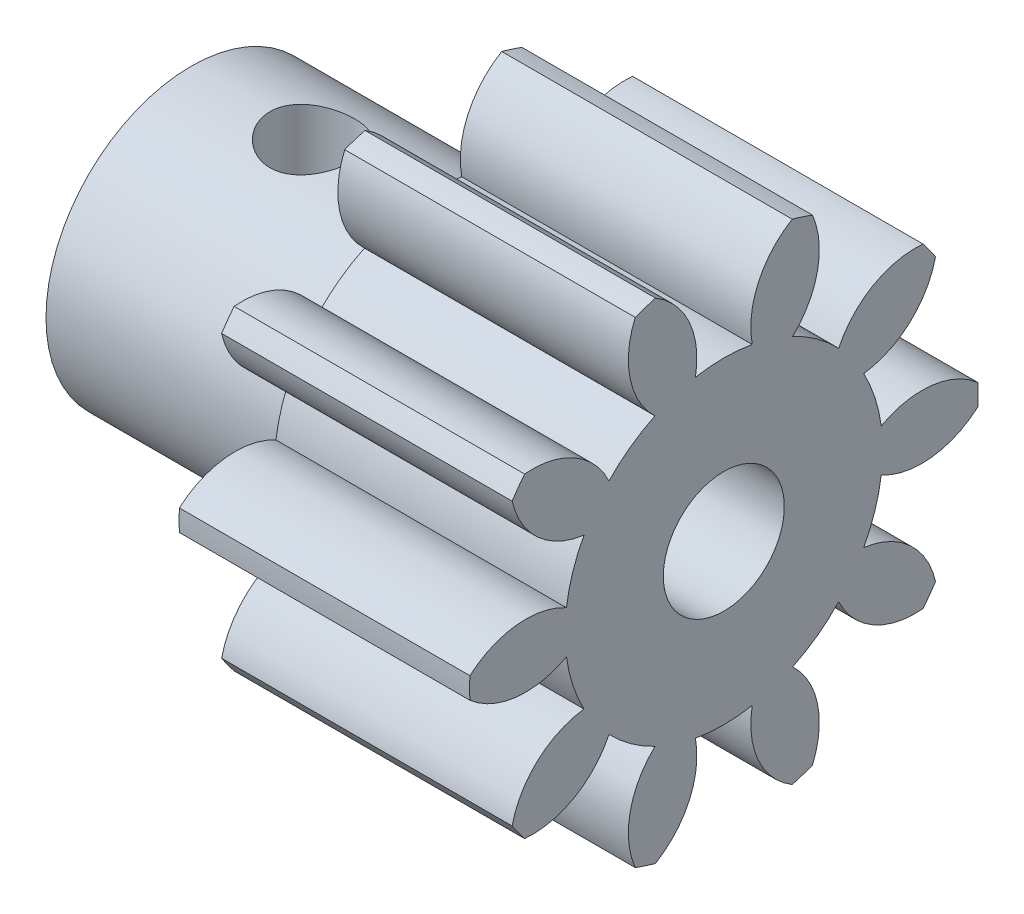
from build123d import *

# Parameters (mm, degrees)
BASPROSKE_W         = 12
BASPROSKE_H         = 10.5
TOOTHCUT_DEPTH      = 13
TEETHCUTS_COUNT     = 10
TEETHCUTS_ANGLE     = 324
BORSKE_R            = 2.5
BORE_DEPTH          = 50.0000508
SKETCH2_R           = 6
SKETCH2_R_2         = 2.75
BOSS_EXTRUDE1_DEPTH = 10
CUT_EXTRUDE1_DEPTH  = 10


with BuildPart() as part:
    # BasProSke → Base-Revolve (revolve)
    with BuildSketch(Plane(origin=(0, 0, 0), x_dir=(1, 0, 0), z_dir=(0, 1, 0))):
        with Locations((6, 5.25)):
            Rectangle(BASPROSKE_W, BASPROSKE_H)
    revolve(axis=Axis((-10, 0, 0), (1, 0, 0)))

    # TooCutSke → ToothCut (cut, through all)
    with BuildSketch(Plane(origin=(0, 0, 0), x_dir=(0, 0, -1), z_dir=(1, 0, 0))):
        with BuildLine():
            ThreePointArc((1.173901537, 6.455636098), (0, 6.5615), (-1.173901537, 6.455636098))
            ThreePointArc((-1.173901537, 6.455636098), (-1.430021039, 8.560346018), (-2.854248526, 10.131007379))
            ThreePointArc((-2.854248526, 10.131007379), (0, 10.5254), (2.854248526, 10.131007379))
            ThreePointArc((2.854248526, 10.131007379), (1.430021039, 8.560346018), (1.173901537, 6.455636098))
        make_face()
    toothcut = extrude(amount=TOOTHCUT_DEPTH, mode=Mode.SUBTRACT)

    # TeethCuts: ToothCut ×10 about axis
    teethcuts_axis = Axis((-10, 0, 0), (1, 0, 0))
    for i in range(1, TEETHCUTS_COUNT):
        add(toothcut.rotate(teethcuts_axis, i * TEETHCUTS_ANGLE / (TEETHCUTS_COUNT - 1)), mode=Mode.SUBTRACT)

    # BorSke → Bore (cut, symmetric)
    with BuildSketch(Plane(origin=(0, 0, 0), x_dir=(0, 0, -1), z_dir=(1, 0, 0))):
        Circle(BORSKE_R)
    extrude(amount=BORE_DEPTH, both=True, mode=Mode.SUBTRACT)

    # Sketch2 → Boss-Extrude1 (add)
    with BuildSketch(Plane.ZY):
        Circle(SKETCH2_R)
        Circle(SKETCH2_R_2, mode=Mode.SUBTRACT)
        with BuildLine():
            ThreePointArc((1.58113883, 2.25), (0.829156198, 2.62202212), (0, 2.75))
            Line((0, 2.75), (0, 2.5))
            ThreePointArc((0, 2.5), (0.559016994, 2.436698586), (1.089724736, 2.25))
            Line((1.089724736, 2.25), (1.58113883, 2.25))
        make_face()
        with BuildLine():
            Line((0, 2.5), (0, 2.75))
            ThreePointArc((0, 2.75), (-0.829156198, 2.62202212), (-1.58113883, 2.25))
            Line((-1.58113883, 2.25), (-1.089724736, 2.25))
            ThreePointArc((-1.089724736, 2.25), (-0.559016994, 2.436698586), (0, 2.5))
        make_face()
        with BuildLine():
            ThreePointArc((1.089724736, 2.25), (0.559016994, 2.436698586), (0, 2.5))
            Line((0, 2.5), (0, 2.25))
            Line((0, 2.25), (1.089724736, 2.25))
        make_face()
        with BuildLine():
            Line((0, 2.25), (0, 2.5))
            ThreePointArc((0, 2.5), (-0.559016994, 2.436698586), (-1.089724736, 2.25))
            Line((-1.089724736, 2.25), (0, 2.25))
        make_face()
    extrude(amount=BOSS_EXTRUDE1_DEPTH)

    # Sketch4 → Cut-Extrude1 (cut)
    with BuildSketch(Plane(origin=(0, 0, 0), x_dir=(1, 0, 0), z_dir=(0, 1, 0))):
        with BuildLine():
            ThreePointArc((-3.25, 0), (-5, 1.75), (-6.75, 0))
            Line((-6.75, 0), (-3.25, 0))
        make_face()
        with BuildLine():
            Line((-3.25, 0), (-6.75, 0))
            ThreePointArc((-6.75, 0), (-5, -1.75), (-3.25, 0))
        make_face()
    extrude(amount=CUT_EXTRUDE1_DEPTH, mode=Mode.SUBTRACT)


solid = part.part
